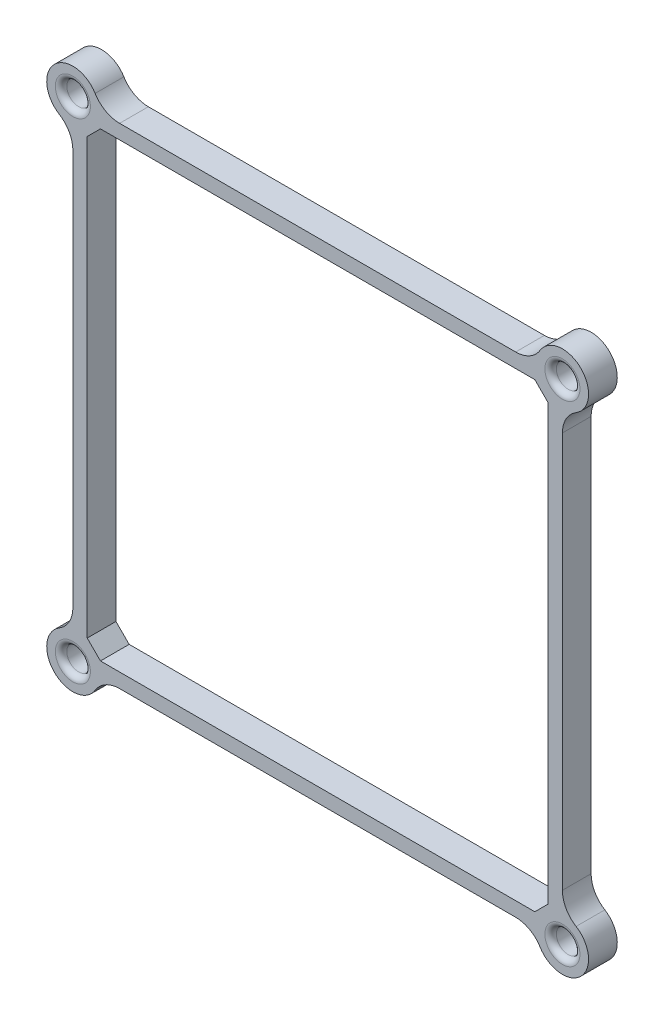
from build123d import *

# Parameters (mm, degrees)
SKETCH1_W           = 80.2
SKETCH1_H           = 80.2
SKETCH1_R           = 2.05
BOSS_EXTRUDE1_DEPTH = 5
CHAMFER1_SIZE       = 2.3
FILLET1_R           = 5
FILLET2_R           = 1
SKETCH2_R           = 4.55
BOSS_EXTRUDE2_DEPTH = 1


with BuildPart() as part:
    # Sketch1 → Boss-Extrude1 (new body)
    with BuildSketch(Plane.XY):
        with BuildLine():
            ThreePointArc((82.7, -2.05), (85.917335854, 5.717335854), (78.15, 2.5))
            Line((78.15, 2.5), (2.05, 2.5))
            ThreePointArc((2.05, 2.5), (-5.717335854, 5.717335854), (-2.5, -2.05))
            Line((-2.5, -2.05), (-2.5, -78.15))
            ThreePointArc((-2.5, -78.15), (-5.717335854, -85.917335854), (2.05, -82.7))
            Line((2.05, -82.7), (78.15, -82.7))
            ThreePointArc((78.15, -82.7), (85.917335854, -85.917335854), (82.7, -78.15))
            Line((82.7, -78.15), (82.7, -2.05))
        make_face()
        with Locations((40.1, -40.1)):
            Rectangle(SKETCH1_W, SKETCH1_H, mode=Mode.SUBTRACT)
        with Locations((82.7, -82.7)):
            Circle(SKETCH1_R, mode=Mode.SUBTRACT)
        with Locations((-2.5, -82.7)):
            Circle(SKETCH1_R, mode=Mode.SUBTRACT)
        with Locations((82.7, 2.5)):
            Circle(SKETCH1_R, mode=Mode.SUBTRACT)
        with Locations((-2.5, 2.5)):
            Circle(SKETCH1_R, mode=Mode.SUBTRACT)
    extrude(amount=BOSS_EXTRUDE1_DEPTH)

    # Chamfer1
    chamfer1_edges = [part.edges().sort_by_distance(p)[0] for p in [
        (0, 0, 2.5),
        (0, -80.2, 2.5),
        (80.2, -80.2, 2.5),
        (80.2, 0, 2.5),
    ]]
    chamfer(chamfer1_edges, length=CHAMFER1_SIZE)

    # Fillet1
    fillet1_edges = [part.edges().sort_by_distance(p)[0] for p in [
        (2.05, 2.5, 2.5),
        (78.15, 2.5, 2.5),
        (82.7, -2.05, 2.5),
        (82.7, -78.15, 2.5),
        (78.15, -82.7, 2.5),
        (2.05, -82.7, 2.5),
        (-2.5, -78.15, 2.5),
        (-2.5, -2.05, 2.5),
    ]]
    fillet(fillet1_edges, radius=FILLET1_R)

    # Fillet2
    fillet2_edges = [part.edges().sort_by_distance(p)[0] for p in [
        (80.65, 2.5, 5),
        (80.65, -82.7, 5),
        (-4.55, 2.5, 5),
        (-4.55, -82.7, 5),
    ]]
    fillet(fillet2_edges, radius=FILLET2_R)

    # Sketch2 → Boss-Extrude2 (add)
    with BuildSketch(Plane(origin=(0, 0, 0), x_dir=(-1, 0, 0), z_dir=(0, 0, -1))):
        with Locations((-82.7, 2.5)):
            Circle(SKETCH2_R)
        with Locations((2.5, 2.5)):
            Circle(SKETCH2_R)
        with Locations((2.5, -82.7)):
            Circle(SKETCH2_R)
        with Locations((-82.7, -82.7)):
            Circle(SKETCH2_R)
    extrude(amount=-BOSS_EXTRUDE2_DEPTH)


solid = part.part
